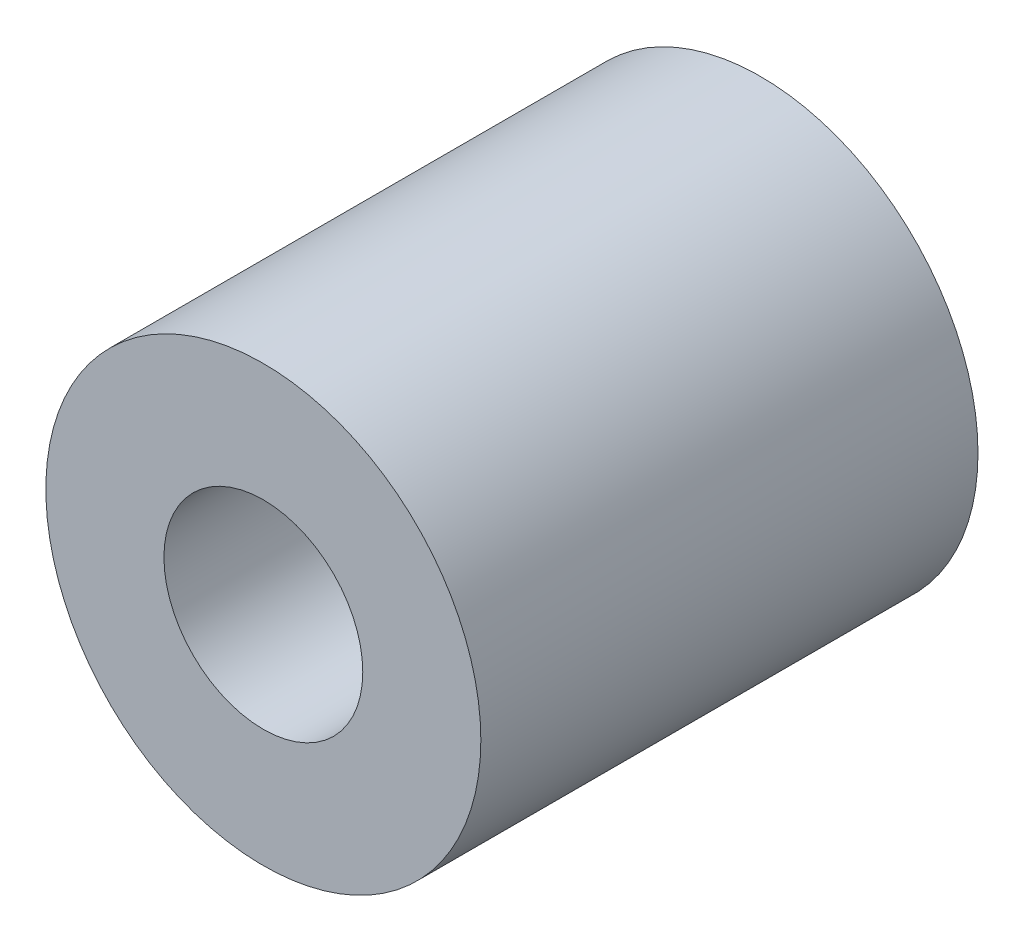
from build123d import *

# Parameters (mm, degrees)
SKETCH_1_R      = 3.5
SKETCH_1_R_2    = 1.6
EXTRUDE_1_DEPTH = 4


with BuildPart() as part:
    # 草图1 → 凸台-拉伸1 (new body, symmetric)
    with BuildSketch(Plane.XY):
        Circle(SKETCH_1_R)
        Circle(SKETCH_1_R_2, mode=Mode.SUBTRACT)
    extrude(amount=EXTRUDE_1_DEPTH, both=True)


solid = part.part
